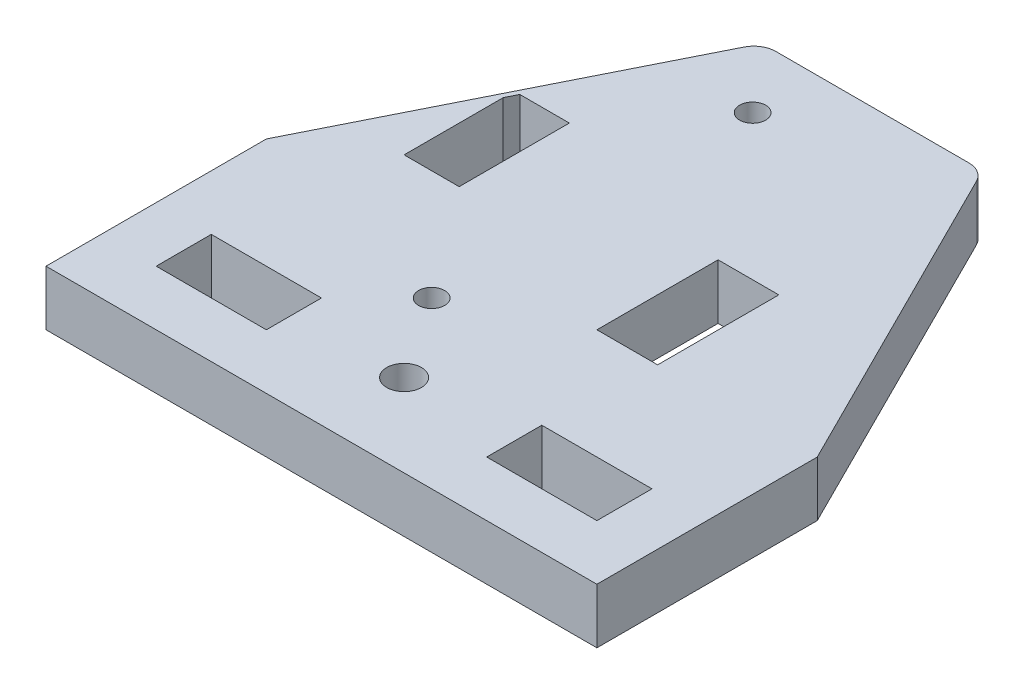
from build123d import *

# Parameters (mm, degrees)
SKETCH2_R               = 2
SKETCH2_R_2             = 1.5
SKETCH2_W               = 12.7
SKETCH2_H               = 6.35
SKETCH2_W_2             = 7
SKETCH2_H_2             = 13.97
BOSS_EXTRUDE1_DEPTH     = 6.35
CUT_EXTRUDE7_DEPTH      = 6.35
CUT_EXTRUDE8_DEPTH      = 1
CUT_EXTRUDE8_DEPTH_BACK = 6.35
CUT_EXTRUDE_THIN1_DEPTH = 6.35


with BuildPart() as part:
    # Sketch2 → Boss-Extrude1 (new body)
    with BuildSketch(Plane(origin=(0, 0, 0), x_dir=(1, 0, 0), z_dir=(0, 1, 0))):
        Polygon((0, 25.4), (25.4, 76.2), (38.1, 76.2), (63.5, 25.4), (63.5, 0), (0, 0), align=None)
        with Locations((31.75, 9.525)):
            Circle(SKETCH2_R, mode=Mode.SUBTRACT)
        with Locations((25.4, 19.05)):
            Circle(SKETCH2_R_2, mode=Mode.SUBTRACT)
        with Locations((25.4, 56.05)):
            Circle(SKETCH2_R_2, mode=Mode.SUBTRACT)
        with Locations((12.7, 9.525)):
            Rectangle(SKETCH2_W, SKETCH2_H, mode=Mode.SUBTRACT)
        with Locations((50.8, 9.525)):
            Rectangle(SKETCH2_W, SKETCH2_H, mode=Mode.SUBTRACT)
        with Locations((41.6, 32.385)):
            Rectangle(SKETCH2_W_2, SKETCH2_H_2, mode=Mode.SUBTRACT)
    extrude(amount=BOSS_EXTRUDE1_DEPTH)

    # Sketch3 → Cut-Extrude7 (cut)
    with BuildSketch(Plane(origin=(0, 6.35, 0), x_dir=(1, 0, 0), z_dir=(0, 1, 0))):
        Polygon((10.16, 44.45), (15.875, 44.45), (15.875, 31.75), (9.525, 31.75), (9.525, 43.18), align=None)
    extrude(amount=-CUT_EXTRUDE7_DEPTH, mode=Mode.SUBTRACT)

    # Sketch4 → Cut-Extrude8 (cut, two sides)
    with BuildSketch(Plane(origin=(0, 6.35, 0), x_dir=(1, 0, 0), z_dir=(0, 1, 0))) as cut_extrude8_sk:
        Polygon((-145.97325632, 63.5), (19.05, 63.5), (44.45, 63.5), (209.47325632, 63.5), (209.47325632, 393.54651264), (-145.97325632, 393.54651264), align=None)
    extrude(amount=CUT_EXTRUDE8_DEPTH, mode=Mode.SUBTRACT)
    extrude(cut_extrude8_sk.sketch, amount=-CUT_EXTRUDE8_DEPTH_BACK, mode=Mode.SUBTRACT)

    # Sketch5 → Cut-Extrude-Thin1 (cut)
    with BuildSketch(Plane(origin=(0, 6.35, 0), x_dir=(1, 0, 0), z_dir=(0, 1, 0))):
        with BuildLine():
            ThreePointArc((45.152038734, 62.095922533), (44.215550693, 63.120653053), (42.880193669, 63.5))
            Line((42.880193669, 63.5), (42.880193669, 66.04))
            ThreePointArc((42.880193669, 66.04), (45.550907718, 65.281306106), (47.423883799, 63.231845065))
            Line((47.423883799, 63.231845065), (45.152038734, 62.095922533))
        make_face()
        with BuildLine():
            ThreePointArc((20.619806331, 63.5), (19.284449307, 63.120653053), (18.347961266, 62.095922533))
            Line((18.347961266, 62.095922533), (16.076116201, 63.231845065))
            ThreePointArc((16.076116201, 63.231845065), (17.949092282, 65.281306106), (20.619806331, 66.04))
            Line((20.619806331, 66.04), (20.619806331, 63.5))
        make_face()
    extrude(amount=-CUT_EXTRUDE_THIN1_DEPTH, mode=Mode.SUBTRACT)


solid = part.part
